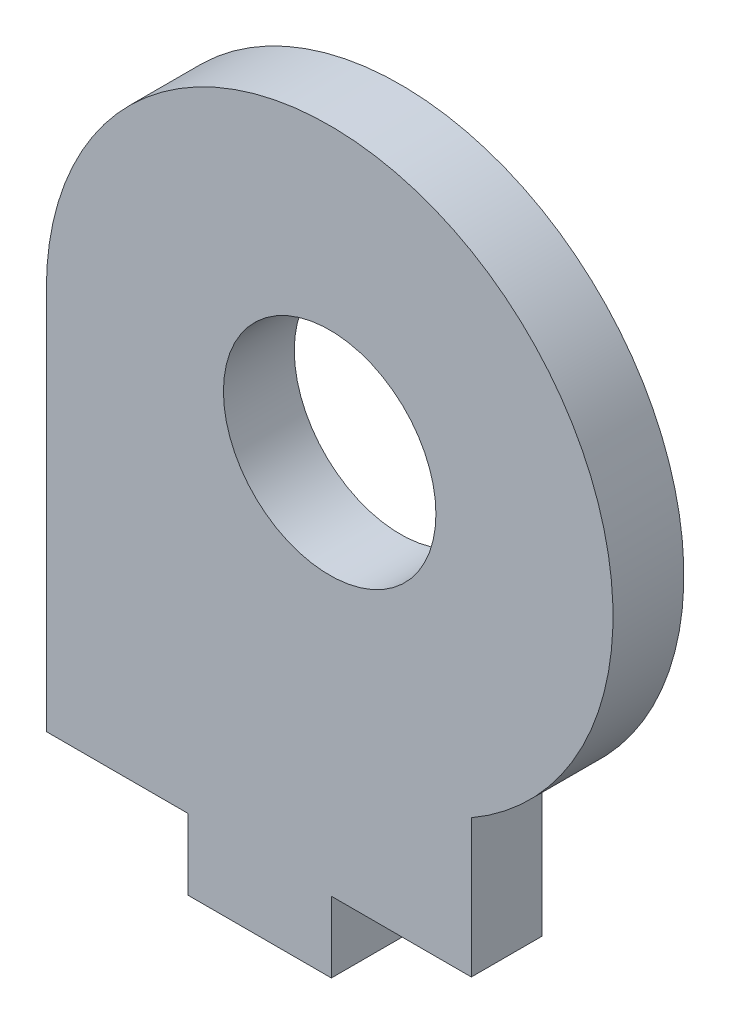
from build123d import *

# Parameters (mm, degrees)
SKETCH1_R           = 4.7625
BOSS_EXTRUDE1_DEPTH = 3.175
SKETCH2_W           = 6.35
SKETCH2_H           = 3.175
SKETCH2_W_2         = 6.2738
CUT_EXTRUDE1_DEPTH  = 3.175


with BuildPart() as part:
    # Sketch1 → Boss-Extrude1 (new body)
    with BuildSketch(Plane.XY):
        with BuildLine():
            Line((7.987675642, 20.35683), (7.987675642, 0))
            Line((7.987675642, 0), (27.037675642, 0))
            Line((27.037675642, 0), (27.037675642, 9.358307372))
            ThreePointArc((27.037675642, 9.358307372), (27.037675642, 31.355352628), (7.987675642, 20.35683))
        make_face()
        with Locations((20.687675642, 20.35683)):
            Circle(SKETCH1_R, mode=Mode.SUBTRACT)
    extrude(amount=BOSS_EXTRUDE1_DEPTH)

    # Sketch2 → Cut-Extrude1 (cut)
    with BuildSketch(Plane.XZ):
        with Locations((11.162675642, 1.5875)):
            Rectangle(SKETCH2_W, SKETCH2_H)
        with Locations((23.900775642, 1.5875)):
            Rectangle(SKETCH2_W_2, SKETCH2_H)
    extrude(amount=-CUT_EXTRUDE1_DEPTH, mode=Mode.SUBTRACT)


solid = part.part
